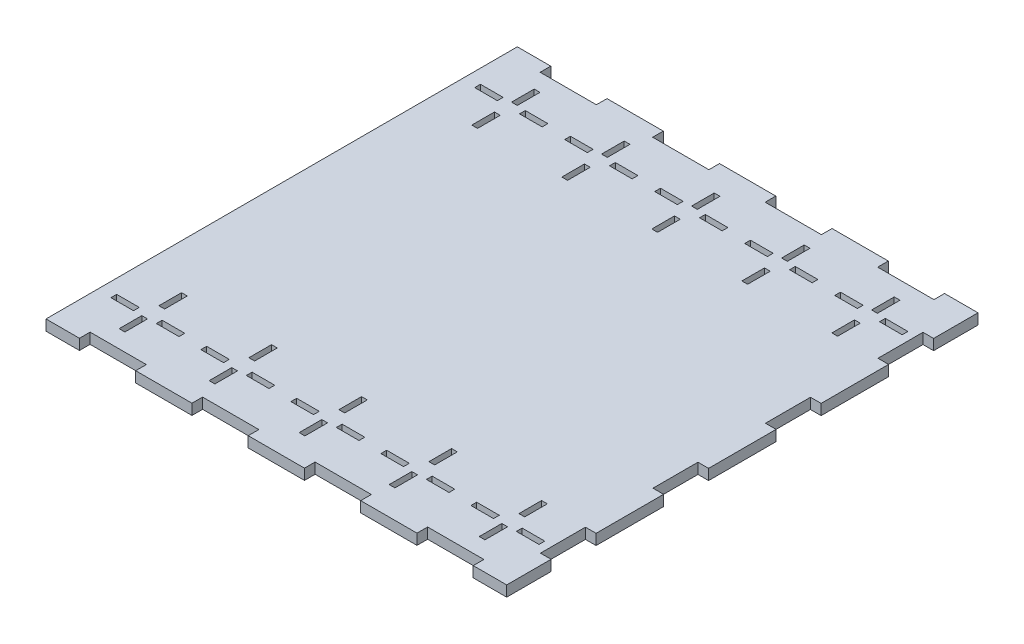
from build123d import *

# Parameters (mm, degrees)
SKETCH1_W           = 260
SKETCH1_H           = 266
BOSS_EXTRUDE1_DEPTH = 6
SKETCH2_W           = 31.75
SKETCH2_H           = 6
SKETCH2_W_2         = 6
SKETCH2_H_2         = 25.4
TAB_CUT_OUTS_DEPTH  = 6
SKETCH4_W           = 12.7762
SKETCH4_H           = 3.2512
SKETCH4_W_2         = 3.2512
SKETCH4_H_2         = 12.7762
CUT_EXTRUDE1_DEPTH  = 7


with BuildPart() as part:
    # Sketch1 → Boss-Extrude1 (new body)
    with BuildSketch(Plane(origin=(0, 0, 0), x_dir=(1, 0, 0), z_dir=(0, 1, 0))):
        Rectangle(SKETCH1_W, SKETCH1_H)
    extrude(amount=BOSS_EXTRUDE1_DEPTH)

    # Sketch2 → Tab Cut Outs (cut)
    with BuildSketch(Plane(origin=(0, 6, 0), x_dir=(1, 0, 0), z_dir=(0, 1, 0))):
        with Locations((95.25, 130)):
            Rectangle(SKETCH2_W, SKETCH2_H)
        with Locations((-31.75, 130)):
            Rectangle(SKETCH2_W, SKETCH2_H)
        with Locations((-95.25, 130)):
            Rectangle(SKETCH2_W, SKETCH2_H)
        with Locations((31.75, 130)):
            Rectangle(SKETCH2_W, SKETCH2_H)
        with Locations((31.75, -130)):
            Rectangle(SKETCH2_W, SKETCH2_H)
        with Locations((95.25, -130)):
            Rectangle(SKETCH2_W, SKETCH2_H)
        with Locations((-95.25, -130)):
            Rectangle(SKETCH2_W, SKETCH2_H)
        with Locations((-31.75, -130)):
            Rectangle(SKETCH2_W, SKETCH2_H)
        with Locations((127, -95.25)):
            Rectangle(SKETCH2_W_2, SKETCH2_H_2)
        with Locations((127, 31.75)):
            Rectangle(SKETCH2_W_2, SKETCH2_H_2)
        with Locations((127, 95.25)):
            Rectangle(SKETCH2_W_2, SKETCH2_H_2)
        with Locations((127, -31.75)):
            Rectangle(SKETCH2_W_2, SKETCH2_H_2)
    extrude(amount=-TAB_CUT_OUTS_DEPTH, mode=Mode.SUBTRACT)

    # Sketch4 → Cut-Extrude1 (cut, through all)
    with BuildSketch(Plane(origin=(0, 6, 0), x_dir=(1, 0, 0), z_dir=(0, 1, 0))):
        with Locations((-64.9125, 102.6668)):
            Rectangle(SKETCH4_W, SKETCH4_H)
        with Locations((-102.9744, 88.3031)):
            Rectangle(SKETCH4_W_2, SKETCH4_H_2)
        with Locations((-102.9744, 110.7313)):
            Rectangle(SKETCH4_W_2, SKETCH4_H_2)
        with Locations((-52.1744, 110.7313)):
            Rectangle(SKETCH4_W_2, SKETCH4_H_2)
        with Locations((-115.7125, 102.6668)):
            Rectangle(SKETCH4_W, SKETCH4_H)
        with Locations((-90.2363, 102.479993419)):
            Rectangle(SKETCH4_W, SKETCH4_H)
        with Locations((-39.4363, 102.479993419)):
            Rectangle(SKETCH4_W, SKETCH4_H)
        with Locations((-52.1744, 88.3031)):
            Rectangle(SKETCH4_W_2, SKETCH4_H_2)
        with Locations((-14.1125, 102.6668)):
            Rectangle(SKETCH4_W, SKETCH4_H)
        with Locations((-1.3744, 110.7313)):
            Rectangle(SKETCH4_W_2, SKETCH4_H_2)
        with Locations((11.3637, 102.479993419)):
            Rectangle(SKETCH4_W, SKETCH4_H)
        with Locations((-1.3744, 88.3031)):
            Rectangle(SKETCH4_W_2, SKETCH4_H_2)
        with Locations((36.6875, 102.6668)):
            Rectangle(SKETCH4_W, SKETCH4_H)
        with Locations((49.4256, 110.7313)):
            Rectangle(SKETCH4_W_2, SKETCH4_H_2)
        with Locations((62.1637, 102.479993419)):
            Rectangle(SKETCH4_W, SKETCH4_H)
        with Locations((49.4256, 88.3031)):
            Rectangle(SKETCH4_W_2, SKETCH4_H_2)
        with Locations((87.4875, 102.6668)):
            Rectangle(SKETCH4_W, SKETCH4_H)
        with Locations((100.2256, 110.7313)):
            Rectangle(SKETCH4_W_2, SKETCH4_H_2)
        with Locations((112.9637, 102.479993419)):
            Rectangle(SKETCH4_W, SKETCH4_H)
        with Locations((100.2256, 88.3031)):
            Rectangle(SKETCH4_W_2, SKETCH4_H_2)
        with Locations((-52.1744, -88.3031)):
            Rectangle(SKETCH4_W_2, SKETCH4_H_2)
        with Locations((-39.4363, -102.479993419)):
            Rectangle(SKETCH4_W, SKETCH4_H)
        with Locations((-52.1744, -110.7313)):
            Rectangle(SKETCH4_W_2, SKETCH4_H_2)
        with Locations((-64.9125, -102.6668)):
            Rectangle(SKETCH4_W, SKETCH4_H)
        with Locations((-1.3744, -88.3031)):
            Rectangle(SKETCH4_W_2, SKETCH4_H_2)
        with Locations((11.3637, -102.479993419)):
            Rectangle(SKETCH4_W, SKETCH4_H)
        with Locations((-1.3744, -110.7313)):
            Rectangle(SKETCH4_W_2, SKETCH4_H_2)
        with Locations((-14.1125, -102.6668)):
            Rectangle(SKETCH4_W, SKETCH4_H)
        with Locations((49.4256, -88.3031)):
            Rectangle(SKETCH4_W_2, SKETCH4_H_2)
        with Locations((62.1637, -102.479993419)):
            Rectangle(SKETCH4_W, SKETCH4_H)
        with Locations((49.4256, -110.7313)):
            Rectangle(SKETCH4_W_2, SKETCH4_H_2)
        with Locations((36.6875, -102.6668)):
            Rectangle(SKETCH4_W, SKETCH4_H)
        with Locations((112.9637, -102.479993419)):
            Rectangle(SKETCH4_W, SKETCH4_H)
        with Locations((100.2256, -88.3031)):
            Rectangle(SKETCH4_W_2, SKETCH4_H_2)
        with Locations((100.2256, -110.7313)):
            Rectangle(SKETCH4_W_2, SKETCH4_H_2)
        with Locations((87.4875, -102.6668)):
            Rectangle(SKETCH4_W, SKETCH4_H)
        with Locations((-102.9744, -88.3031)):
            Rectangle(SKETCH4_W_2, SKETCH4_H_2)
        with Locations((-90.2363, -102.479993419)):
            Rectangle(SKETCH4_W, SKETCH4_H)
        with Locations((-102.9744, -110.7313)):
            Rectangle(SKETCH4_W_2, SKETCH4_H_2)
        with Locations((-115.7125, -102.6668)):
            Rectangle(SKETCH4_W, SKETCH4_H)
    extrude(amount=-CUT_EXTRUDE1_DEPTH, mode=Mode.SUBTRACT)


solid = part.part
